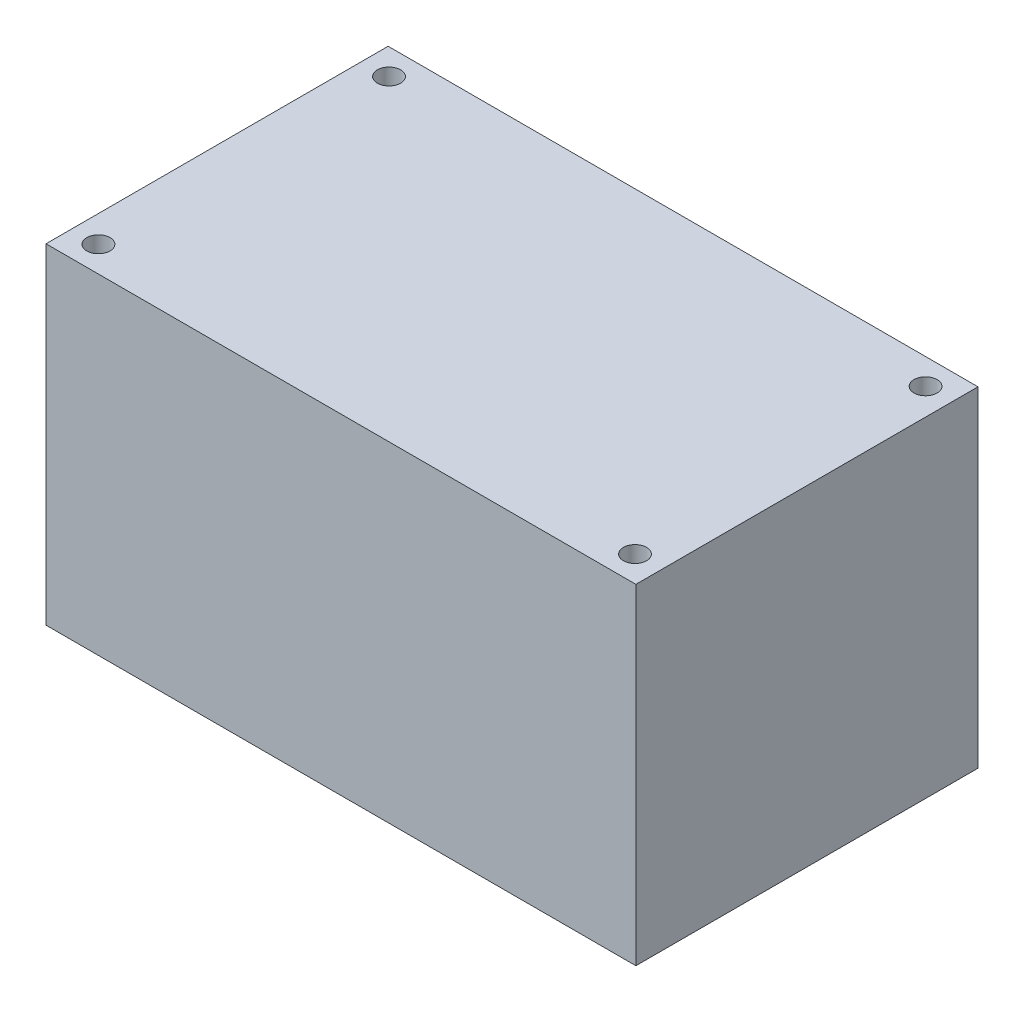
from build123d import *

# Parameters (mm, degrees)
SKETCH2_W               = 63.5
SKETCH2_H               = 36.83
BOSS_EXTRUDE1_DEPTH     = 17.78
SKETCH3_R               = 1.25
CUT_EXTRUDE1_DEPTH      = 1
CUT_EXTRUDE1_DEPTH_BACK = 36.56


with BuildPart() as part:
    # Sketch2 → Boss-Extrude1 (new body, symmetric)
    with BuildSketch(Plane(origin=(0, 0, 0), x_dir=(1, 0, 0), z_dir=(0, 1, 0))):
        Rectangle(SKETCH2_W, SKETCH2_H)
    extrude(amount=BOSS_EXTRUDE1_DEPTH, both=True)

    # Sketch3 → Cut-Extrude1 (cut, two sides)
    with BuildSketch(Plane(origin=(0, 17.78, 0), x_dir=(1, 0, 0), z_dir=(0, 1, 0))) as cut_extrude1_sk:
        with Locations((-28.88075, 15.64005)):
            Circle(SKETCH3_R)
        with Locations((28.88075, 15.64005)):
            Circle(SKETCH3_R)
        with Locations((28.88075, -15.64005)):
            Circle(SKETCH3_R)
        with Locations((-28.88075, -15.64005)):
            Circle(SKETCH3_R)
    extrude(amount=CUT_EXTRUDE1_DEPTH, mode=Mode.SUBTRACT)
    extrude(cut_extrude1_sk.sketch, amount=-CUT_EXTRUDE1_DEPTH_BACK, mode=Mode.SUBTRACT)


solid = part.part
